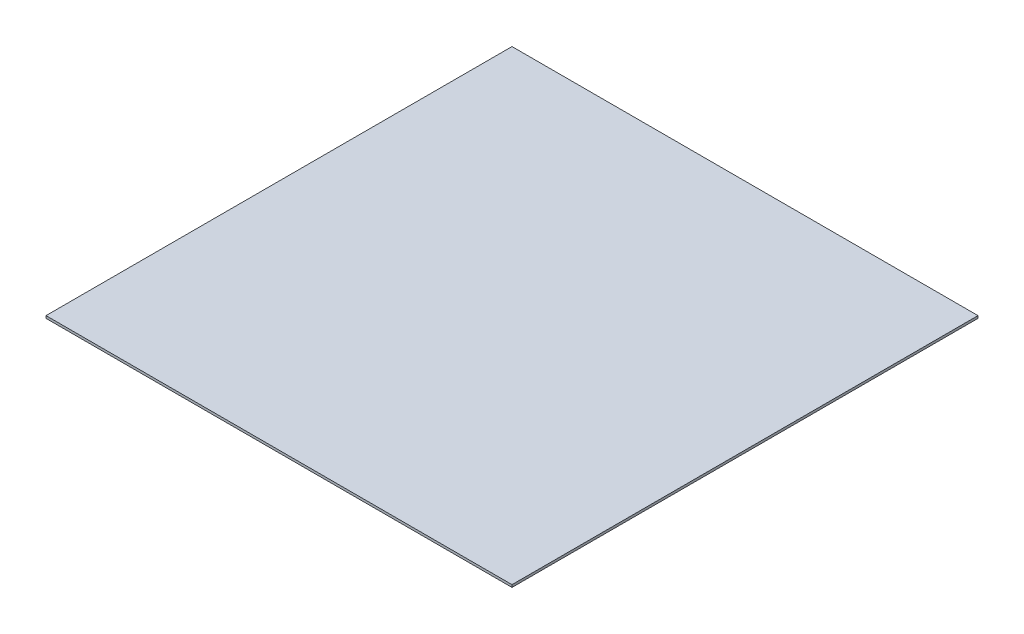
from build123d import *

# Parameters (mm, degrees)
SKETCH1_W      = 609.6
SKETCH1_H      = 609.6
EXTRUDE1_DEPTH = 3.175


with BuildPart() as part:
    # Sketch1 → Extrude1 (new body)
    with BuildSketch(Plane(origin=(0, 0, 0), x_dir=(1, 0, 0), z_dir=(0, 1, 0))):
        Rectangle(SKETCH1_W, SKETCH1_H)
    extrude(amount=-EXTRUDE1_DEPTH)


solid = part.part
